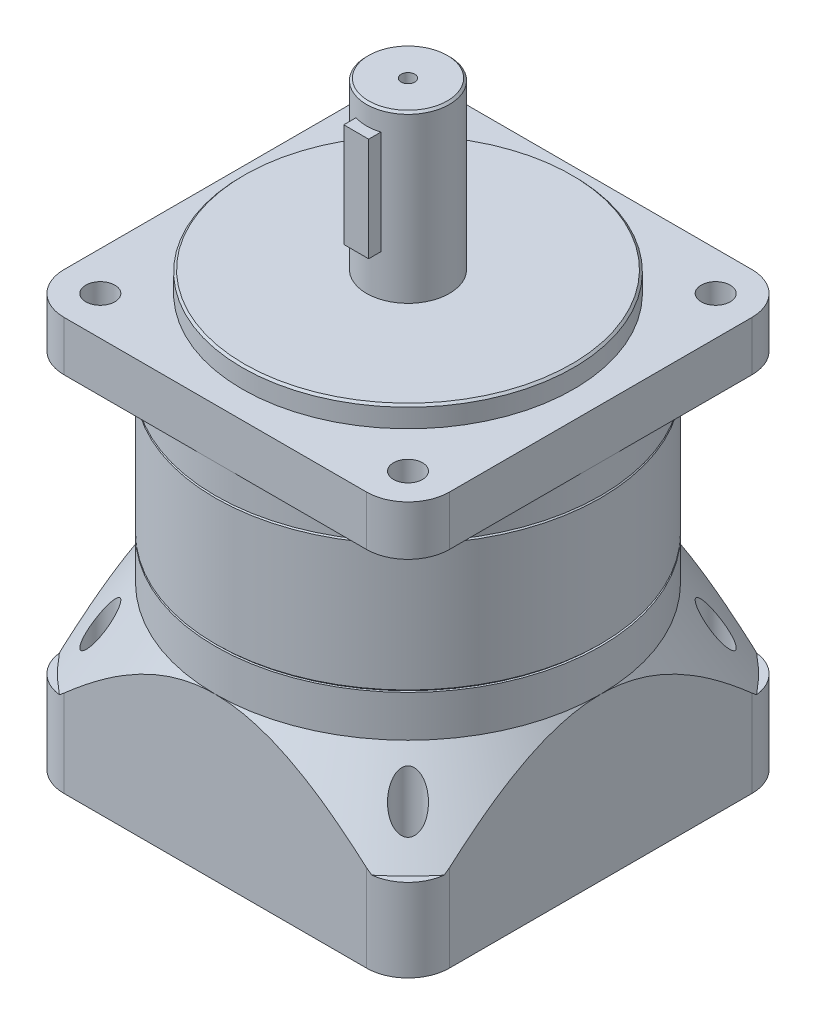
from build123d import *

# Parameters (mm, degrees)
EXTRUDE_1_DEPTH               = 49
CUT_EXTRUDE_START             = -10
SKETCH_2_OUTSIDE_W            = 123.07
SKETCH_2_OUTSIDE_H            = 123.07
SKETCH_2_OUTSIDE_R            = 46.5
CUT_EXTRUDE_3_DEPTH           = 10
CUT_EXTRUDE_3_OTHER_WAY_DEPTH = 19
CUT_EXTRUDE_3_OTHER_WAY_TAPER = 35
SKETCH_3_R                    = 46.5
EXTRUDE_2_DEPTH               = 31.5
SKETCH_4_R                    = 46.5
EXTRUDE_3_DEPTH               = 19
CHAMFER_1_SIZE                = 0.5
SKETCH_6_R                    = 40
EXTRUDE_5_DEPTH               = 5
SKETCH_7_R                    = 10
EXTRUDE_6_DEPTH               = 40
CHAMFER_2_SIZE                = 0.5
SKETCH_10_W                   = 6
SKETCH_10_H                   = 25
EXTRUDE_7_DEPTH               = 12.5
SKETCH_11_R                   = 35
CUT_EXTRUDE_4_DEPTH           = 6
SKETCH_12_R                   = 10
CUT_EXTRUDE_5_DEPTH           = 40
SKETCH_15_R                   = 44.756471123
EXTRUDE_8_DEPTH               = 12
SKETCH_16_W                   = 3.5
SKETCH_16_H                   = 99.5
PATTERN_CIRCULAR_1_COUNT      = 4


with BuildPart() as part:
    # 草圖1 → 填料-伸長1 (new body)
    with BuildSketch(Plane(origin=(0, 0, 0), x_dir=(1, 0, 0), z_dir=(0, 1, 0))):
        with BuildLine():
            Line((-36.5, -46.5), (36.5, -46.5))
            ThreePointArc((36.5, -46.5), (43.571067812, -43.571067812), (46.5, -36.5))
            Line((46.5, -36.5), (46.5, 36.5))
            ThreePointArc((46.5, 36.5), (43.571067812, 43.571067812), (36.5, 46.5))
            Line((36.5, 46.5), (-36.5, 46.5))
            ThreePointArc((-36.5, 46.5), (-43.571067812, 43.571067812), (-46.5, 36.5))
            Line((-46.5, 36.5), (-46.5, -36.5))
            ThreePointArc((-46.5, -36.5), (-43.571067812, -43.571067812), (-36.5, -46.5))
        make_face()
    extrude(amount=EXTRUDE_1_DEPTH)

    # 草圖2 outside → 除料-伸長3 (cut)
    with BuildSketch(Plane(origin=(0, 49, 0), x_dir=(1, 0, 0), z_dir=(0, 1, 0)).offset(CUT_EXTRUDE_START)):
        Rectangle(SKETCH_2_OUTSIDE_W, SKETCH_2_OUTSIDE_H)
        with Locations(Location((0, 0, 0), (0, 0, 270))):  # turned: the seam where the file's is
            Circle(SKETCH_2_OUTSIDE_R, mode=Mode.SUBTRACT)
    extrude(amount=CUT_EXTRUDE_3_DEPTH, mode=Mode.SUBTRACT)

    # 草圖2 outside → 除料-伸長3 other way (cut)
    with BuildSketch(Plane(origin=(0, 49, 0), x_dir=(1, 0, 0), z_dir=(0, 1, 0)).offset(CUT_EXTRUDE_START)):
        Rectangle(SKETCH_2_OUTSIDE_W, SKETCH_2_OUTSIDE_H)
        with Locations(Location((0, 0, 0), (0, 0, 270))):  # turned: the seam where the file's is
            Circle(SKETCH_2_OUTSIDE_R, mode=Mode.SUBTRACT)
    extrude(amount=-CUT_EXTRUDE_3_OTHER_WAY_DEPTH, taper=CUT_EXTRUDE_3_OTHER_WAY_TAPER, mode=Mode.SUBTRACT)

    # 草圖11 → 除料-伸長4 (cut)
    with BuildSketch(Plane.XZ):
        with Locations(Location((0, 0, 0), (0, 0, 270))):  # turned: the seam where the file's is
            Circle(SKETCH_11_R)
    extrude(amount=-CUT_EXTRUDE_4_DEPTH, mode=Mode.SUBTRACT)

    # 草圖12 → 除料-伸長5 (cut)
    with BuildSketch(Plane.XZ.offset(-6)):
        with Locations(Location((0, 0, 0), (0, 0, 90))):  # turned: the seam where the file's is
            Circle(SKETCH_12_R)
    extrude(amount=-CUT_EXTRUDE_5_DEPTH, mode=Mode.SUBTRACT)


with BuildPart() as body_2:
    # 草圖3 → 填料-伸長2 (new body)
    with BuildSketch(Plane(origin=(0, 49, 0), x_dir=(1, 0, 0), z_dir=(0, 1, 0))):
        with Locations(Location((0, 0, 0), (0, 0, 270))):  # turned: the seam where the file's is
            Circle(SKETCH_3_R)
    extrude(amount=EXTRUDE_2_DEPTH)

    # 導角1
    chamfer_1_edges = [body_2.edges().sort_by_distance(p)[0] for p in [
        (0, 49, -46.5),
        (0, 80.5, -46.5),
    ]]
    chamfer(chamfer_1_edges, length=CHAMFER_1_SIZE)


with BuildPart() as body_3:
    # 草圖4 → 填料-伸長3 (new body)
    with BuildSketch(Plane(origin=(0, 80.5, 0), x_dir=(1, 0, 0), z_dir=(0, 1, 0))):
        with Locations(Location((0, 0, 0), (0, 0, 270))):  # turned: the seam where the file's is
            Circle(SKETCH_4_R)
    extrude(amount=EXTRUDE_3_DEPTH)

    # 草圖6 → 填料-伸長5 (add)
    with BuildSketch(Plane(origin=(0, 99.5, 0), x_dir=(1, 0, 0), z_dir=(0, 1, 0))):
        with Locations(Location((0, 0, 0), (0, 0, 270))):  # turned: the seam where the file's is
            Circle(SKETCH_6_R)
    extrude(amount=EXTRUDE_5_DEPTH)

    # 草圖7 → 填料-伸長6 (add)
    with BuildSketch(Plane(origin=(0, 104.5, 0), x_dir=(1, 0, 0), z_dir=(0, 1, 0))):
        with Locations(Location((0, 0, 0), (0, 0, 270))):  # turned: the seam where the file's is
            Circle(SKETCH_7_R)
    extrude(amount=EXTRUDE_6_DEPTH)

    # 導角2
    chamfer_2_edges = [body_3.edges().sort_by_distance(p)[0] for p in [
        (0, 144.5, -10),
        (0, 99.5, -46.5),
        (0, 104.5, -40),
    ]]
    chamfer(chamfer_2_edges, length=CHAMFER_2_SIZE)

    # 草圖10 → 填料-伸長7 (add)
    with BuildSketch(Plane.XY):
        with Locations((0, 127)):
            Rectangle(SKETCH_10_W, SKETCH_10_H)
    extrude(amount=EXTRUDE_7_DEPTH)

    # 草圖13 → M4x0.7 螺紋孔1 (revolve, cut)
    with BuildSketch(Plane(origin=(0, 144.5, 0), x_dir=(0, 0, 1), z_dir=(1, 0, 0))):
        Polygon((0, 0), (0, 11.091420021), (1.65, 10.1), (1.65, 0), align=None)
    revolve(axis=Axis((0, 150.85, 0), (0, -1, 0)), mode=Mode.SUBTRACT)

    # 草圖15 → 填料-伸長8 (add)
    with BuildSketch(Plane(origin=(0, 99.5, 0), x_dir=(1, 0, 0), z_dir=(0, 1, 0))):
        with BuildLine():
            Line((-36.5, -46.5), (36.5, -46.5))
            ThreePointArc((36.5, -46.5), (43.571067812, -43.571067812), (46.5, -36.5))
            Line((46.5, -36.5), (46.5, 36.5))
            ThreePointArc((46.5, 36.5), (43.571067812, 43.571067812), (36.5, 46.5))
            Line((36.5, 46.5), (-36.5, 46.5))
            ThreePointArc((-36.5, 46.5), (-43.571067812, 43.571067812), (-46.5, 36.5))
            Line((-46.5, 36.5), (-46.5, -36.5))
            ThreePointArc((-46.5, -36.5), (-43.571067812, -43.571067812), (-36.5, -46.5))
        make_face()
        Circle(SKETCH_15_R, mode=Mode.SUBTRACT)
    extrude(amount=-EXTRUDE_8_DEPTH)


with BuildPart() as hole_wizard_7_0_7_3_tool:
    # 草圖16 → Ø7.0 (7) 直徑孔3 (revolve)
    with BuildSketch(Plane(origin=(37.123106012, 99.5, -37.123106012), x_dir=(0, 0, 1), z_dir=(1, 0, 0))):
        with Locations((1.75, 49.75)):
            Rectangle(SKETCH_16_W, SKETCH_16_H)
    hole_wizard_7_0_7_3 = revolve(axis=Axis((37.123106012, 105.85, -37.123106012), (0, -1, 0)))


with BuildPart() as part_1:
    add(part.part)

    # Ø7.0 (7) 直徑孔3: cut by hole_wizard_7_0_7_3_tool
    add(hole_wizard_7_0_7_3_tool.part, mode=Mode.SUBTRACT)


with BuildPart() as body_3_1:
    add(body_3.part)

    # Ø7.0 (7) 直徑孔3: cut by hole_wizard_7_0_7_3_tool
    add(hole_wizard_7_0_7_3_tool.part, mode=Mode.SUBTRACT)


with BuildPart() as pattern_circular_1_tool:
    # 環狀複製排列1: Ø7.0 (7) 直徑孔3 ×4 about axis
    pattern_circular_1_axis = Axis((0, 0, 0), (0, 1, 0))
    for i in range(1, PATTERN_CIRCULAR_1_COUNT):
        add(hole_wizard_7_0_7_3.rotate(pattern_circular_1_axis, i * 360 / PATTERN_CIRCULAR_1_COUNT))


with BuildPart() as part_2:
    add(part_1.part)

    # 環狀複製排列1: cut by pattern_circular_1_tool
    add(pattern_circular_1_tool.part, mode=Mode.SUBTRACT)


with BuildPart() as body_3_2:
    add(body_3_1.part)

    # 環狀複製排列1: cut by pattern_circular_1_tool
    add(pattern_circular_1_tool.part, mode=Mode.SUBTRACT)


solid = Compound([body_2.part, part_2.part, body_3_2.part])
